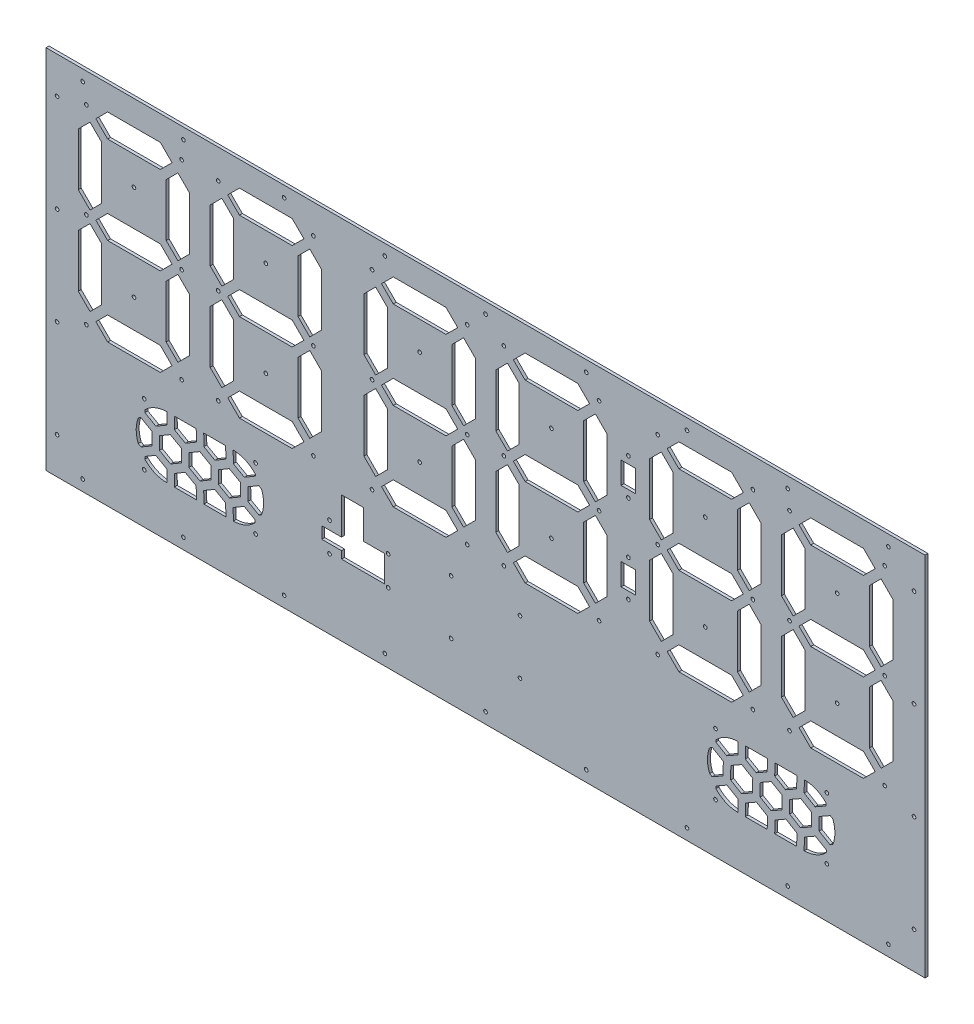
from build123d import *

# Parameters (mm, degrees)
CROQUIS2_W              = 600
CROQUIS2_H              = 250
SALIENTE_EXTRUIR1_DEPTH = 4
CROQUIS4_R              = 1.25
CROQUIS4_W              = 10
CROQUIS4_H              = 15
CORTAR_EXTRUIR4_DEPTH   = 2
CROQUIS5_R              = 1.25
CORTAR_EXTRUIR3_DEPTH   = 326.024614453
CROQUIS8_R              = 1.25
CORTAR_EXTRUIR6_DEPTH   = 326.024614453
CROQUIS11_R             = 1.25
CORTAR_EXTRUIR9_DEPTH   = 326.024614453
CORTAR_EXTRUIR7_DEPTH   = 326.024614453
CROQUIS13_R             = 1.25
CORTAR_EXTRUIR10_DEPTH  = 326.024614453
CORTAR_EXTRUIR11_DEPTH  = 2
CORTAR_EXTRUIR12_DEPTH  = 326.006153788
CROQUIS16_W             = 2
CROQUIS16_H             = 250
CORTAR_EXTRUIR13_DEPTH  = 613.89558654


with BuildPart() as part:
    # Croquis2 → Saliente-Extruir1 (new body)
    with BuildSketch(Plane.XY):
        Rectangle(CROQUIS2_W, CROQUIS2_H)
    extrude(amount=SALIENTE_EXTRUIR1_DEPTH)

    # Croquis4 → Cortar-Extruir4 (cut)
    with BuildSketch(Plane(origin=(0, 0, 0), x_dir=(-1, 0, 0), z_dir=(0, 0, -1))):
        with Locations((-77.5, -25)):
            Circle(CROQUIS4_R)
        with Locations((-12.5, -25)):
            Circle(CROQUIS4_R)
        with Locations((-12.5, 40)):
            Circle(CROQUIS4_R)
        with Locations((-45, 7.5)):
            Circle(CROQUIS4_R)
        with Locations((-77.5, 40)):
            Circle(CROQUIS4_R)
        with Locations((-45, 72.5)):
            Circle(CROQUIS4_R)
        with Locations((-77.5, 105)):
            Circle(CROQUIS4_R)
        with Locations((-12.5, 105)):
            Circle(CROQUIS4_R)
        with Locations((12.5, -25)):
            Circle(CROQUIS4_R)
        with Locations((77.5, -25)):
            Circle(CROQUIS4_R)
        with Locations((77.5, 40)):
            Circle(CROQUIS4_R)
        with Locations((45, 7.5)):
            Circle(CROQUIS4_R)
        with Locations((12.5, 40)):
            Circle(CROQUIS4_R)
        with Locations((45, 72.5)):
            Circle(CROQUIS4_R)
        with Locations((12.5, 105)):
            Circle(CROQUIS4_R)
        with Locations((77.5, 105)):
            Circle(CROQUIS4_R)
        with Locations((117.5, -25)):
            Circle(CROQUIS4_R)
        with Locations((182.5, -25)):
            Circle(CROQUIS4_R)
        with Locations((182.5, 40)):
            Circle(CROQUIS4_R)
        with Locations((150, 7.5)):
            Circle(CROQUIS4_R)
        with Locations((117.5, 40)):
            Circle(CROQUIS4_R)
        with Locations((150, 72.5)):
            Circle(CROQUIS4_R)
        with Locations((117.5, 105)):
            Circle(CROQUIS4_R)
        with Locations((182.5, 105)):
            Circle(CROQUIS4_R)
        with Locations((-182.5, -25)):
            Circle(CROQUIS4_R)
        with Locations((-117.5, -25)):
            Circle(CROQUIS4_R)
        with Locations((-117.5, 40)):
            Circle(CROQUIS4_R)
        with Locations((-150, 7.5)):
            Circle(CROQUIS4_R)
        with Locations((-182.5, 40)):
            Circle(CROQUIS4_R)
        with Locations((-150, 72.5)):
            Circle(CROQUIS4_R)
        with Locations((-182.5, 105)):
            Circle(CROQUIS4_R)
        with Locations((-117.5, 105)):
            Circle(CROQUIS4_R)
        with Locations((207.5, -25)):
            Circle(CROQUIS4_R)
        with Locations((272.5, -25)):
            Circle(CROQUIS4_R)
        with Locations((272.5, 40)):
            Circle(CROQUIS4_R)
        with Locations((240, 7.5)):
            Circle(CROQUIS4_R)
        with Locations((207.5, 40)):
            Circle(CROQUIS4_R)
        with Locations((240, 72.5)):
            Circle(CROQUIS4_R)
        with Locations((207.5, 105)):
            Circle(CROQUIS4_R)
        with Locations((272.5, 105)):
            Circle(CROQUIS4_R)
        with Locations((-272.5, -25)):
            Circle(CROQUIS4_R)
        with Locations((-207.5, -25)):
            Circle(CROQUIS4_R)
        with Locations((-207.5, 40)):
            Circle(CROQUIS4_R)
        with Locations((-240, 7.5)):
            Circle(CROQUIS4_R)
        with Locations((-272.5, 40)):
            Circle(CROQUIS4_R)
        with Locations((-240, 72.5)):
            Circle(CROQUIS4_R)
        with Locations((-272.5, 105)):
            Circle(CROQUIS4_R)
        with Locations((-207.5, 105)):
            Circle(CROQUIS4_R)
        Polygon((221.999998415, 92.000001585), (213.999998415, 100.000001585), (221.999998415, 108.000001585), (257.999998415, 108.000001585), (265.999998415, 100.000001585), (257.999998415, 92.000001585), align=None)
        Polygon((-262, -8), (-270, -16), (-278, -8), (-278, 28), (-270, 36), (-262, 28), align=None)
        Polygon((-258.000001585, 92.000001585), (-266.000001585, 100.000001585), (-258.000001585, 108.000001585), (-222.000001585, 108.000001585), (-214.000001585, 100.000001585), (-222.000001585, 92.000001585), align=None)
        Polygon((-168.000001585, -12.000001585), (-176.000001585, -20.000001585), (-168.000001585, -28.000001585), (-132.000001585, -28.000001585), (-124.000001585, -20.000001585), (-132.000001585, -12.000001585), align=None)
        Polygon((222, 32), (214, 40), (222, 48), (258, 48), (266, 40), (258, 32), align=None)
        Polygon((-168.000001585, 92.000001585), (-176.000001585, 100.000001585), (-168.000001585, 108.000001585), (-132.000001585, 108.000001585), (-124.000001585, 100.000001585), (-132.000001585, 92.000001585), align=None)
        Polygon((221.999998415, -12.000001585), (213.999998415, -20.000001585), (221.999998415, -28.000001585), (257.999998415, -28.000001585), (265.999998415, -20.000001585), (257.999998415, -12.000001585), align=None)
        Polygon((262, -8), (270, -16), (278, -8), (278, 28), (270, 36), (262, 28), align=None)
        Polygon((218, 88), (210, 96), (202, 88), (202, 52), (210, 44), (218, 52), align=None)
        Polygon((218, -8), (210, -16), (202, -8), (202, 28), (210, 36), (218, 28), align=None)
        Polygon((-128, -8), (-120, -16), (-112, -8), (-112, 28), (-120, 36), (-128, 28), align=None)
        Polygon((-168, 32), (-176, 40), (-168, 48), (-132, 48), (-124, 40), (-132, 32), align=None)
        Polygon((-262, 88), (-270, 96), (-278, 88), (-278, 52), (-270, 44), (-262, 52), align=None)
        Polygon((262, 88), (270, 96), (278, 88), (278, 52), (270, 44), (262, 52), align=None)
        Polygon((-218, 88), (-210, 96), (-202, 88), (-202, 52), (-210, 44), (-218, 52), align=None)
        Polygon((-258, 32), (-266, 40), (-258, 48), (-222, 48), (-214, 40), (-222, 32), align=None)
        Polygon((-218, -8), (-210, -16), (-202, -8), (-202, 28), (-210, 36), (-218, 28), align=None)
        Polygon((-258.000001585, -12.000001585), (-266.000001585, -20.000001585), (-258.000001585, -28.000001585), (-222.000001585, -28.000001585), (-214.000001585, -20.000001585), (-222.000001585, -12.000001585), align=None)
        Polygon((128, 88), (120, 96), (112, 88), (112, 52), (120, 44), (128, 52), align=None)
        Polygon((131.999998415, 92.000001585), (123.999998415, 100.000001585), (131.999998415, 108.000001585), (167.999998415, 108.000001585), (175.999998415, 100.000001585), (167.999998415, 92.000001585), align=None)
        Polygon((128, -8), (120, -16), (112, -8), (112, 28), (120, 36), (128, 28), align=None)
        Polygon((131.999998415, -12.000001585), (123.999998415, -20.000001585), (131.999998415, -28.000001585), (167.999998415, -28.000001585), (175.999998415, -20.000001585), (167.999998415, -12.000001585), align=None)
        Polygon((132, 32), (124, 40), (132, 48), (168, 48), (176, 40), (168, 32), align=None)
        Polygon((172, -8), (180, -16), (188, -8), (188, 28), (180, 36), (172, 28), align=None)
        Polygon((-128, 88), (-120, 96), (-112, 88), (-112, 52), (-120, 44), (-128, 52), align=None)
        Polygon((-172, -8), (-180, -16), (-188, -8), (-188, 28), (-180, 36), (-172, 28), align=None)
        Polygon((-172, 88), (-180, 96), (-188, 88), (-188, 52), (-180, 44), (-172, 52), align=None)
        Polygon((172, 88), (180, 96), (188, 88), (188, 52), (180, 44), (172, 52), align=None)
        Polygon((-67, 88), (-75, 96), (-83, 88), (-83, 52), (-75, 44), (-67, 52), align=None)
        Polygon((-63.000001585, -12.000001585), (-71.000001585, -20.000001585), (-63.000001585, -28.000001585), (-27.000001585, -28.000001585), (-19.000001585, -20.000001585), (-27.000001585, -12.000001585), align=None)
        Polygon((-63, 32), (-71, 40), (-63, 48), (-27, 48), (-19, 40), (-27, 32), align=None)
        Polygon((-23, -8), (-15, -16), (-7, -8), (-7, 28), (-15, 36), (-23, 28), align=None)
        Polygon((23, 88), (15, 96), (7, 88), (7, 52), (15, 44), (23, 52), align=None)
        Polygon((-23, 88), (-15, 96), (-7, 88), (-7, 52), (-15, 44), (-23, 52), align=None)
        Polygon((-63.000001585, 92.000001585), (-71.000001585, 100.000001585), (-63.000001585, 108.000001585), (-27.000001585, 108.000001585), (-19.000001585, 100.000001585), (-27.000001585, 92.000001585), align=None)
        Polygon((67, 88), (75, 96), (83, 88), (83, 52), (75, 44), (67, 52), align=None)
        Polygon((23, -8), (15, -16), (7, -8), (7, 28), (15, 36), (23, 28), align=None)
        Polygon((-67, -8), (-75, -16), (-83, -8), (-83, 28), (-75, 36), (-67, 28), align=None)
        Polygon((26.999998415, 92.000001585), (18.999998415, 100.000001585), (26.999998415, 108.000001585), (62.999998415, 108.000001585), (70.999998415, 100.000001585), (62.999998415, 92.000001585), align=None)
        Polygon((27, 32), (19, 40), (27, 48), (63, 48), (71, 40), (63, 32), align=None)
        Polygon((67, -8), (75, -16), (83, -8), (83, 28), (75, 36), (67, 28), align=None)
        Polygon((26.999998415, -12.000001585), (18.999998415, -20.000001585), (26.999998415, -28.000001585), (62.999998415, -28.000001585), (70.999998415, -20.000001585), (62.999998415, -12.000001585), align=None)
        with Locations((-97.5, 10)):
            Rectangle(CROQUIS4_W, CROQUIS4_H)
        with Locations((-97.5, 70)):
            Rectangle(CROQUIS4_W, CROQUIS4_H)
    extrude(amount=-CORTAR_EXTRUIR4_DEPTH, mode=Mode.SUBTRACT)

    # Croquis5 → Cortar-Extruir3 (cut, through all)
    with BuildSketch(Plane.XY):
        with Locations((-292.5, 100)):
            Circle(CROQUIS5_R)
        with Locations(Location((-292.5, -100, 0), (0, 0, 180))):
            Circle(CROQUIS5_R)
        with Locations((-292.5, 33.333333333)):
            Circle(CROQUIS5_R)
        with Locations((-292.5, -33.333333333)):
            Circle(CROQUIS5_R)
        with Locations(Location((292.5, -33.333333333, 0), (0, 0, 180))):
            Circle(CROQUIS5_R)
        with Locations(Location((292.5, 33.333333333, 0), (0, 0, 180))):
            Circle(CROQUIS5_R)
        with Locations((292.5, -100)):
            Circle(CROQUIS5_R)
        with Locations(Location((292.5, 100, 0), (0, 0, 180))):
            Circle(CROQUIS5_R)
        with Locations((-275, 117.5)):
            Circle(CROQUIS5_R)
        with Locations((-206.25, 117.5)):
            Circle(CROQUIS5_R)
        with Locations((-137.5, 117.5)):
            Circle(CROQUIS5_R)
        with Locations((-68.75, 117.5)):
            Circle(CROQUIS5_R)
        with Locations(Location((68.75, 117.5, 0), (0, 0, 180))):
            Circle(CROQUIS5_R)
        with Locations(Location((137.5, 117.5, 0), (0, 0, 180))):
            Circle(CROQUIS5_R)
        with Locations(Location((206.25, 117.5, 0), (0, 0, 180))):
            Circle(CROQUIS5_R)
        with Locations(Location((275, 117.5, 0), (0, 0, 180))):
            Circle(CROQUIS5_R)
        with Locations((0, 117.5)):
            Circle(CROQUIS5_R)
        with Locations(Location((0, -117.5, 0), (0, 0, 180))):
            Circle(CROQUIS5_R)
        with Locations((275, -117.5)):
            Circle(CROQUIS5_R)
        with Locations((206.25, -117.5)):
            Circle(CROQUIS5_R)
        with Locations((137.5, -117.5)):
            Circle(CROQUIS5_R)
        with Locations((68.75, -117.5)):
            Circle(CROQUIS5_R)
        with Locations(Location((-68.75, -117.5, 0), (0, 0, 180))):
            Circle(CROQUIS5_R)
        with Locations(Location((-137.5, -117.5, 0), (0, 0, 180))):
            Circle(CROQUIS5_R)
        with Locations(Location((-206.25, -117.5, 0), (0, 0, 180))):
            Circle(CROQUIS5_R)
        with Locations(Location((-275, -117.5, 0), (0, 0, 180))):
            Circle(CROQUIS5_R)
        with Locations(Location((-77.5, -25, 0), (0, 0, 180))):
            Circle(CROQUIS5_R)
        with Locations(Location((-12.5, -25, 0), (0, 0, 180))):
            Circle(CROQUIS5_R)
        with Locations(Location((-12.5, 40, 0), (0, 0, 180))):
            Circle(CROQUIS5_R)
        with Locations(Location((-45, 7.5, 0), (0, 0, 180))):
            Circle(CROQUIS5_R)
        with Locations(Location((-77.5, 40, 0), (0, 0, 180))):
            Circle(CROQUIS5_R)
        with Locations(Location((-45, 72.5, 0), (0, 0, 180))):
            Circle(CROQUIS5_R)
        with Locations(Location((-77.5, 105, 0), (0, 0, 180))):
            Circle(CROQUIS5_R)
        with Locations(Location((-12.5, 105, 0), (0, 0, 180))):
            Circle(CROQUIS5_R)
        with Locations(Location((12.5, -25, 0), (0, 0, 180))):
            Circle(CROQUIS5_R)
        with Locations(Location((77.5, -25, 0), (0, 0, 180))):
            Circle(CROQUIS5_R)
        with Locations(Location((77.5, 40, 0), (0, 0, 180))):
            Circle(CROQUIS5_R)
        with Locations(Location((45, 7.5, 0), (0, 0, 180))):
            Circle(CROQUIS5_R)
        with Locations(Location((12.5, 40, 0), (0, 0, 180))):
            Circle(CROQUIS5_R)
        with Locations(Location((45, 72.5, 0), (0, 0, 180))):
            Circle(CROQUIS5_R)
        with Locations(Location((12.5, 105, 0), (0, 0, 180))):
            Circle(CROQUIS5_R)
        with Locations(Location((77.5, 105, 0), (0, 0, 180))):
            Circle(CROQUIS5_R)
        with Locations(Location((117.5, -25, 0), (0, 0, 180))):
            Circle(CROQUIS5_R)
        with Locations(Location((182.5, -25, 0), (0, 0, 180))):
            Circle(CROQUIS5_R)
        with Locations(Location((182.5, 40, 0), (0, 0, 180))):
            Circle(CROQUIS5_R)
        with Locations(Location((150, 7.5, 0), (0, 0, 180))):
            Circle(CROQUIS5_R)
        with Locations(Location((117.5, 40, 0), (0, 0, 180))):
            Circle(CROQUIS5_R)
        with Locations(Location((150, 72.5, 0), (0, 0, 180))):
            Circle(CROQUIS5_R)
        with Locations(Location((117.5, 105, 0), (0, 0, 180))):
            Circle(CROQUIS5_R)
        with Locations(Location((182.5, 105, 0), (0, 0, 180))):
            Circle(CROQUIS5_R)
        with Locations(Location((-182.5, -25, 0), (0, 0, 180))):
            Circle(CROQUIS5_R)
        with Locations(Location((-117.5, -25, 0), (0, 0, 180))):
            Circle(CROQUIS5_R)
        with Locations(Location((-117.5, 40, 0), (0, 0, 180))):
            Circle(CROQUIS5_R)
        with Locations(Location((-150, 7.5, 0), (0, 0, 180))):
            Circle(CROQUIS5_R)
        with Locations(Location((-182.5, 40, 0), (0, 0, 180))):
            Circle(CROQUIS5_R)
        with Locations(Location((-150, 72.5, 0), (0, 0, 180))):
            Circle(CROQUIS5_R)
        with Locations(Location((-182.5, 105, 0), (0, 0, 180))):
            Circle(CROQUIS5_R)
        with Locations(Location((-117.5, 105, 0), (0, 0, 180))):
            Circle(CROQUIS5_R)
        with Locations(Location((207.5, -25, 0), (0, 0, 180))):
            Circle(CROQUIS5_R)
        with Locations(Location((272.5, -25, 0), (0, 0, 180))):
            Circle(CROQUIS5_R)
        with Locations(Location((272.5, 40, 0), (0, 0, 180))):
            Circle(CROQUIS5_R)
        with Locations(Location((240, 7.5, 0), (0, 0, 180))):
            Circle(CROQUIS5_R)
        with Locations(Location((207.5, 40, 0), (0, 0, 180))):
            Circle(CROQUIS5_R)
        with Locations(Location((240, 72.5, 0), (0, 0, 180))):
            Circle(CROQUIS5_R)
        with Locations(Location((207.5, 105, 0), (0, 0, 180))):
            Circle(CROQUIS5_R)
        with Locations(Location((272.5, 105, 0), (0, 0, 180))):
            Circle(CROQUIS5_R)
        with Locations(Location((-272.5, -25, 0), (0, 0, 180))):
            Circle(CROQUIS5_R)
        with Locations(Location((-207.5, -25, 0), (0, 0, 180))):
            Circle(CROQUIS5_R)
        with Locations(Location((-207.5, 40, 0), (0, 0, 180))):
            Circle(CROQUIS5_R)
        with Locations(Location((-240, 7.5, 0), (0, 0, 180))):
            Circle(CROQUIS5_R)
        with Locations(Location((-272.5, 40, 0), (0, 0, 180))):
            Circle(CROQUIS5_R)
        with Locations(Location((-240, 72.5, 0), (0, 0, 180))):
            Circle(CROQUIS5_R)
        with Locations(Location((-272.5, 105, 0), (0, 0, 180))):
            Circle(CROQUIS5_R)
        with Locations(Location((-207.5, 105, 0), (0, 0, 180))):
            Circle(CROQUIS5_R)
        with Locations((97.5, 22.5)):
            Circle(CROQUIS5_R)
        with Locations((97.5, -2.5)):
            Circle(CROQUIS5_R)
        with Locations(Location((97.5, 57.5, 0), (0, 0, 180))):
            Circle(CROQUIS5_R)
        with Locations(Location((97.5, 82.5, 0), (0, 0, 180))):
            Circle(CROQUIS5_R)
    extrude(amount=CORTAR_EXTRUIR3_DEPTH, mode=Mode.SUBTRACT)

    # Croquis8 → Cortar-Extruir6 (cut, through all)
    with BuildSketch(Plane.XY.offset(4)):
        with Locations((-233, -49)):
            Circle(CROQUIS8_R)
        with Locations((-233, -91)):
            Circle(CROQUIS8_R)
        with Locations((-157, -91)):
            Circle(CROQUIS8_R)
        with Locations((-157, -49)):
            Circle(CROQUIS8_R)
        with Locations(Location((157, -49, 0), (0, 0, 180))):
            Circle(CROQUIS8_R)
        with Locations(Location((157, -91, 0), (0, 0, 180))):
            Circle(CROQUIS8_R)
        with Locations(Location((233, -91, 0), (0, 0, 180))):
            Circle(CROQUIS8_R)
        with Locations(Location((233, -49, 0), (0, 0, 180))):
            Circle(CROQUIS8_R)
    extrude(amount=-CORTAR_EXTRUIR6_DEPTH, mode=Mode.SUBTRACT)

    # Croquis11 → Cortar-Extruir9 (cut, through all)
    with BuildSketch(Plane(origin=(0, 0, 0), x_dir=(-1, 0, 0), z_dir=(0, 0, -1))):
        with Locations((-23.5, -49)):
            Circle(CROQUIS11_R)
        with Locations((23.5, -49)):
            Circle(CROQUIS11_R)
        with Locations((23.5, -86)):
            Circle(CROQUIS11_R)
        with Locations((-23.5, -86)):
            Circle(CROQUIS11_R)
    extrude(amount=-CORTAR_EXTRUIR9_DEPTH, mode=Mode.SUBTRACT)

    # Croquis9 → Cortar-Extruir7 (cut, through all)
    with BuildSketch(Plane.XY.offset(4)):
        Polygon((207.660336161, -65.60072068), (215.200047582, -61.340116065), (222.659695125, -65.739395385), (222.579631247, -74.39927932), (215.039919826, -78.659883935), (207.580272283, -74.260604615), align=None)
        with BuildLine():
            Line((232.539914551, -57.026597388), (232.555325078, -55.359761149))
            ThreePointArc((232.555325078, -55.359761149), (225.723977048, -50.677322197), (217.613479558, -49.000306719))
            Line((217.613479558, -49.000306719), (217.540555588, -56.887922683))
            Line((217.540555588, -56.887922683), (225.00020313, -61.287202004))
            Line((225.00020313, -61.287202004), (232.539914551, -57.026597388))
        make_face()
        Polygon((212.419939167, -57.026597388), (212.494148073, -49), (197.49350701, -49), (197.420580203, -56.887922683), (204.880227746, -61.287202004), align=None)
        Polygon((192.299963782, -57.026597388), (192.374172689, -49), (177.373531625, -49), (177.300604818, -56.887922683), (184.760252361, -61.287202004), align=None)
        with BuildLine():
            ThreePointArc((172.254184004, -49.001438522), (164.047678268, -50.77609326), (157.192316823, -55.623789135))
            Line((157.192316823, -55.623789135), (157.180629434, -56.887922683))
            Line((157.180629434, -56.887922683), (164.640276977, -61.287202004))
            Line((164.640276977, -61.287202004), (172.179988398, -57.026597388))
            Line((172.179988398, -57.026597388), (172.254184004, -49.001438522))
        make_face()
        with BuildLine():
            ThreePointArc((152.911967347, -62.42967976), (151.500005641, -70.03262348), (152.935582835, -77.631143545))
            Line((152.935582835, -77.631143545), (154.679968714, -78.659883935))
            Line((154.679968714, -78.659883935), (162.219680135, -74.39927932))
            Line((162.219680135, -74.39927932), (162.299744014, -65.739395385))
            Line((162.299744014, -65.739395385), (154.840096471, -61.340116065))
            Line((154.840096471, -61.340116065), (152.911967347, -62.42967976))
        make_face()
        with BuildLine():
            ThreePointArc((157.24585479, -84.433005747), (164.052101947, -89.225851121), (172.185803255, -90.997649697))
            Line((172.185803255, -90.997649697), (172.260052276, -82.966713452))
            Line((172.260052276, -82.966713452), (164.800404733, -78.567434132))
            Line((164.800404733, -78.567434132), (157.260693312, -82.828038748))
            Line((157.260693312, -82.828038748), (157.24585479, -84.433005747))
        make_face()
        Polygon((167.420368753, -65.60072068), (174.960080174, -61.340116065), (182.419727717, -65.739395385), (182.339663839, -74.39927932), (174.799952418, -78.659883935), (167.340304875, -74.260604615), align=None)
        Polygon((177.305115847, -91), (192.30575691, -91), (192.38002766, -82.966713452), (184.920380118, -78.567434132), (177.380668697, -82.828038748), align=None)
        Polygon((187.540352457, -65.60072068), (195.080063878, -61.340116065), (202.539711421, -65.739395385), (202.459647543, -74.39927932), (194.919936122, -78.659883935), (187.460288579, -74.260604615), align=None)
        Polygon((197.425091231, -91), (212.425732295, -91), (212.500003045, -82.966713452), (205.040355502, -78.567434132), (197.500644081, -82.828038748), align=None)
        with BuildLine():
            Line((217.620619466, -82.828038748), (217.545067063, -90.9999516))
            ThreePointArc((217.545067063, -90.9999516), (225.725328044, -89.322102746), (232.604979759, -84.589002412))
            Line((232.604979759, -84.589002412), (232.61997843, -82.966713452))
            Line((232.61997843, -82.966713452), (225.160330887, -78.567434132))
            Line((225.160330887, -78.567434132), (217.620619466, -82.828038748))
        make_face()
        with BuildLine():
            Line((235.159903529, -78.659883935), (237.087982246, -77.570348724))
            ThreePointArc((237.087982246, -77.570348724), (238.499954959, -69.967375593), (237.064365996, -62.368826278))
            Line((237.064365996, -62.368826278), (235.320031286, -61.340116065))
            Line((235.320031286, -61.340116065), (227.780319865, -65.60072068))
            Line((227.780319865, -65.60072068), (227.700255986, -74.260604615))
            Line((227.700255986, -74.260604615), (235.159903529, -78.659883935))
        make_face()
        Polygon((-212.500003045, -82.966713452), (-212.425732295, -91), (-197.425091231, -91), (-197.500644081, -82.828038748), (-205.040355502, -78.567434132), align=None)
        Polygon((-192.38002766, -82.966713452), (-192.30575691, -91), (-177.305115847, -91), (-177.380668697, -82.828038748), (-184.920380118, -78.567434132), align=None)
        with BuildLine():
            ThreePointArc((-172.185803255, -90.997649697), (-164.052101947, -89.225851121), (-157.24585479, -84.433005747))
            Line((-157.24585479, -84.433005747), (-157.260693312, -82.828038748))
            Line((-157.260693312, -82.828038748), (-164.800404733, -78.567434132))
            Line((-164.800404733, -78.567434132), (-172.260052276, -82.966713452))
            Line((-172.260052276, -82.966713452), (-172.185803255, -90.997649697))
        make_face()
        with BuildLine():
            ThreePointArc((-152.935582835, -77.631143545), (-151.500005641, -70.03262348), (-152.911967347, -62.42967976))
            Line((-152.911967347, -62.42967976), (-154.840096471, -61.340116065))
            Line((-154.840096471, -61.340116065), (-162.299744014, -65.739395385))
            Line((-162.299744014, -65.739395385), (-162.219680135, -74.39927932))
            Line((-162.219680135, -74.39927932), (-154.679968714, -78.659883935))
            Line((-154.679968714, -78.659883935), (-152.935582835, -77.631143545))
        make_face()
        Polygon((-174.799952418, -78.659883935), (-167.340304875, -74.260604615), (-167.420368753, -65.60072068), (-174.960080174, -61.340116065), (-182.419727717, -65.739395385), (-182.339663839, -74.39927932), align=None)
        Polygon((-194.919936122, -78.659883935), (-187.460288579, -74.260604615), (-187.540352457, -65.60072068), (-195.080063878, -61.340116065), (-202.539711421, -65.739395385), (-202.459647543, -74.39927932), align=None)
        Polygon((-215.039919826, -78.659883935), (-207.580272283, -74.260604615), (-207.660336161, -65.60072068), (-215.200047582, -61.340116065), (-222.659695125, -65.739395385), (-222.579631247, -74.39927932), align=None)
        with BuildLine():
            Line((-232.61997843, -82.966713452), (-232.604979759, -84.589002412))
            ThreePointArc((-232.604979759, -84.589002412), (-225.725328044, -89.322102746), (-217.545067063, -90.9999516))
            Line((-217.545067063, -90.9999516), (-217.620619466, -82.828038748))
            Line((-217.620619466, -82.828038748), (-225.160330887, -78.567434132))
            Line((-225.160330887, -78.567434132), (-232.61997843, -82.966713452))
        make_face()
        with BuildLine():
            Line((-235.320031286, -61.340116065), (-237.064365996, -62.368826278))
            ThreePointArc((-237.064365996, -62.368826278), (-238.499954959, -69.967375593), (-237.087982246, -77.570348724))
            Line((-237.087982246, -77.570348724), (-235.159903529, -78.659883935))
            Line((-235.159903529, -78.659883935), (-227.700255986, -74.260604615))
            Line((-227.700255986, -74.260604615), (-227.780319865, -65.60072068))
            Line((-227.780319865, -65.60072068), (-235.320031286, -61.340116065))
        make_face()
        with BuildLine():
            Line((-217.540555588, -56.887922683), (-217.613479558, -49.000306719))
            ThreePointArc((-217.613479558, -49.000306719), (-225.723977048, -50.677322197), (-232.555325078, -55.359761149))
            Line((-232.555325078, -55.359761149), (-232.539914551, -57.026597388))
            Line((-232.539914551, -57.026597388), (-225.00020313, -61.287202004))
            Line((-225.00020313, -61.287202004), (-217.540555588, -56.887922683))
        make_face()
        Polygon((-197.49350701, -49), (-212.494148073, -49), (-212.419939167, -57.026597388), (-204.880227746, -61.287202004), (-197.420580203, -56.887922683), align=None)
        Polygon((-177.373531625, -49), (-192.374172689, -49), (-192.299963782, -57.026597388), (-184.760252361, -61.287202004), (-177.300604818, -56.887922683), align=None)
        with BuildLine():
            ThreePointArc((-157.192316823, -55.623789135), (-164.047678268, -50.77609326), (-172.254184004, -49.001438522))
            Line((-172.254184004, -49.001438522), (-172.179988398, -57.026597388))
            Line((-172.179988398, -57.026597388), (-164.640276977, -61.287202004))
            Line((-164.640276977, -61.287202004), (-157.180629434, -56.887922683))
            Line((-157.180629434, -56.887922683), (-157.192316823, -55.623789135))
        make_face()
    extrude(amount=-CORTAR_EXTRUIR7_DEPTH, mode=Mode.SUBTRACT)

    # Croquis13 → Cortar-Extruir10 (cut, through all)
    with BuildSketch(Plane(origin=(0, 0, 0), x_dir=(-1, 0, 0), z_dir=(0, 0, -1))):
        with Locations((66.5, -57.5)):
            Circle(CROQUIS13_R)
        with Locations((66.5, -77.5)):
            Circle(CROQUIS13_R)
        with Locations((106.5, -77.5)):
            Circle(CROQUIS13_R)
        with Locations((106.5, -57.5)):
            Circle(CROQUIS13_R)
    extrude(amount=-CORTAR_EXTRUIR10_DEPTH, mode=Mode.SUBTRACT)

    # Croquis14 → Cortar-Extruir11 (cut)
    with BuildSketch(Plane(origin=(0, 0, 0), x_dir=(-1, 0, 0), z_dir=(0, 0, -1))):
        Polygon((68.85, -76.5), (68.85, -58.5), (83.293122568, -58.5), (83.293122568, -53.5), (83.293122568, -38.5), (98.293122568, -38.5), (98.293122568, -53.5), (98.293122568, -63.5), (100.024999998, -63.5), (111.793122568, -63.5), (111.793122568, -71.5), (98.293122568, -71.5), (98.293122568, -76.5), align=None)
    extrude(amount=-CORTAR_EXTRUIR11_DEPTH, mode=Mode.SUBTRACT)

    # Croquis15 → Cortar-Extruir12 (cut, through all)
    with BuildSketch(Plane(origin=(0, 0, 2), x_dir=(-1, 0, 0), z_dir=(0, 0, -1))):
        Polygon((75.776689089, -62.093987059), (70.776689089, -64.980738405), (70.776689089, -70.754241097), (75.776689089, -73.640992443), (80.776689089, -70.754241097), (80.776689089, -64.980738405), align=None)
    extrude(amount=-CORTAR_EXTRUIR12_DEPTH, mode=Mode.SUBTRACT)

    # Croquis16 → Cortar-Extruir13 (cut, through all)
    with BuildSketch(Plane.ZY.offset(300)):
        with Locations((3, 0)):
            Rectangle(CROQUIS16_W, CROQUIS16_H)
    extrude(amount=-CORTAR_EXTRUIR13_DEPTH, mode=Mode.SUBTRACT)


solid = part.part
